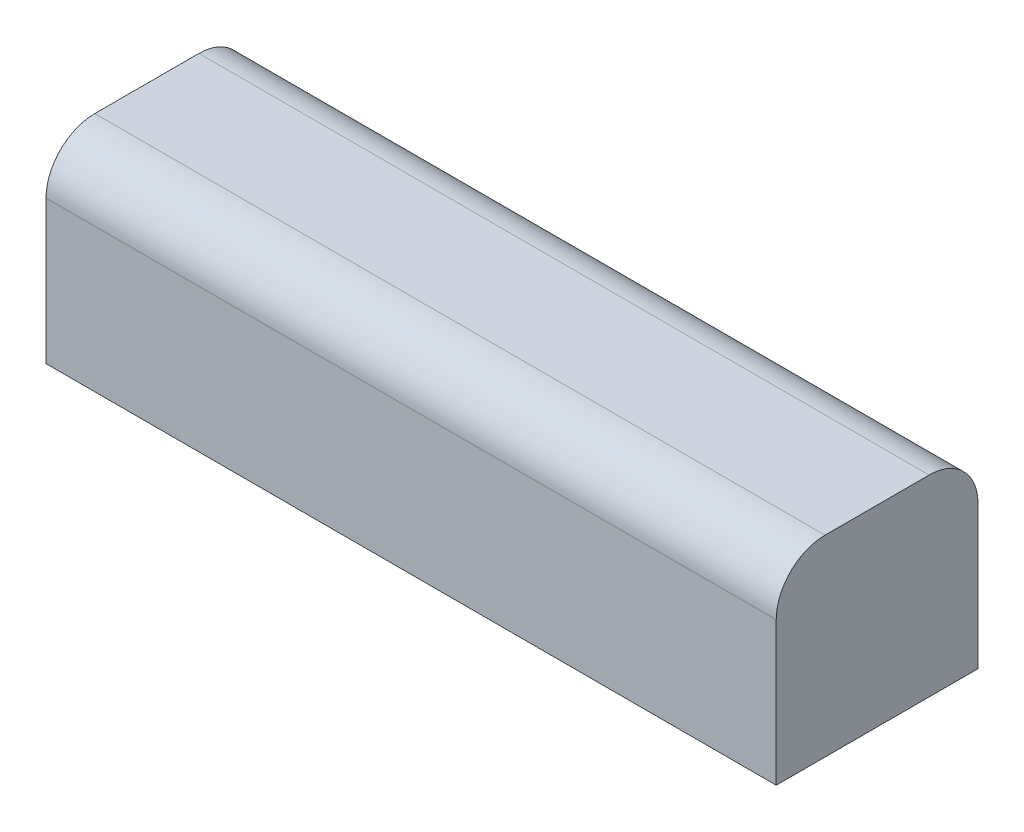
from build123d import *

# Parameters (mm, degrees)
SKETCH1_W           = 76
SKETCH1_H           = 21
BOSS_EXTRUDE1_DEPTH = 20
FILLET1_R           = 5.08
SKETCH2_R           = 1.5
CUT_EXTRUDE1_DEPTH  = 2.54


with BuildPart() as part:
    # Sketch1 → Boss-Extrude1 (new body)
    with BuildSketch(Plane(origin=(0, 0, 0), x_dir=(1, 0, 0), z_dir=(0, 1, 0))):
        Rectangle(SKETCH1_W, SKETCH1_H)
    extrude(amount=BOSS_EXTRUDE1_DEPTH)

    # Fillet1
    fillet1_edges = [part.edges().sort_by_distance(p)[0] for p in [
        (0, 20, 10.5),
        (0, 20, -10.5),
    ]]
    fillet(fillet1_edges, radius=FILLET1_R)

    # Sketch2 → Cut-Extrude1 (cut)
    with BuildSketch(Plane.XZ):
        Circle(SKETCH2_R)
    extrude(amount=-CUT_EXTRUDE1_DEPTH, mode=Mode.SUBTRACT)


solid = part.part
